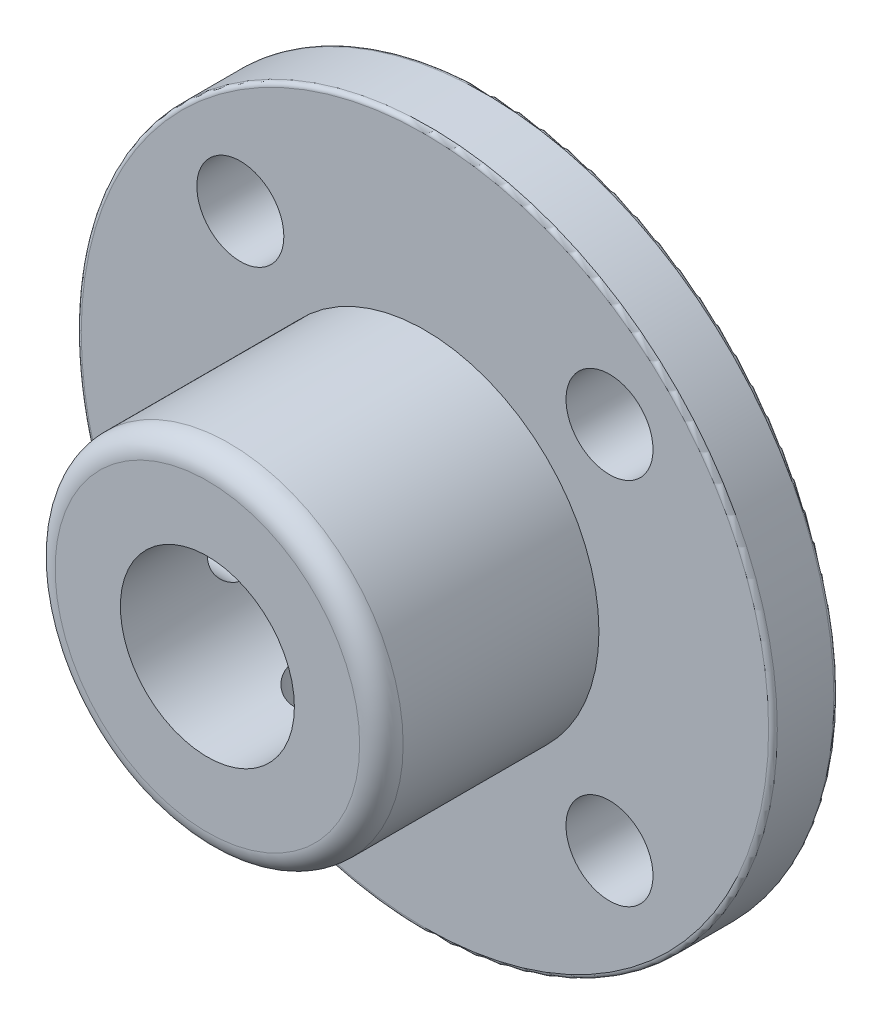
from build123d import *

# Parameters (mm, degrees)
SKETCH1_R           = 16
BOSS_EXTRUDE1_DEPTH = 3
SKETCH2_R           = 8
BOSS_EXTRUDE2_DEPTH = 10
SKETCH3_R           = 4
CUT_EXTRUDE1_DEPTH  = 14
SKETCH4_R           = 2
CUT_EXTRUDE2_DEPTH  = 4
FILLET1_R           = 1
SKETCH5_R           = 1.5
CUT_EXTRUDE3_DEPTH  = 9
SKETCH6_R           = 1.5
CUT_EXTRUDE4_DEPTH  = 9
FILLET2_R           = 0.2


with BuildPart() as part:
    # Sketch1 → Boss-Extrude1 (new body)
    with BuildSketch(Plane.XY):
        Circle(SKETCH1_R)
    extrude(amount=BOSS_EXTRUDE1_DEPTH)

    # Sketch2 → Boss-Extrude2 (add)
    with BuildSketch(Plane.XY.offset(3)):
        Circle(SKETCH2_R)
    extrude(amount=BOSS_EXTRUDE2_DEPTH)

    # Sketch3 → Cut-Extrude1 (cut, through all)
    with BuildSketch(Plane.XY.offset(13)):
        Circle(SKETCH3_R)
    extrude(amount=-CUT_EXTRUDE1_DEPTH, mode=Mode.SUBTRACT)

    # Sketch4 → Cut-Extrude2 (cut, through all)
    with BuildSketch(Plane.XY.offset(3)):
        with Locations((-8.485281374, 8.485281374)):
            Circle(SKETCH4_R)
        with Locations((8.485281374, 8.485281374)):
            Circle(SKETCH4_R)
        with Locations((8.485281374, -8.485281374)):
            Circle(SKETCH4_R)
        with Locations((-8.485281374, -8.485281374)):
            Circle(SKETCH4_R)
    extrude(amount=-CUT_EXTRUDE2_DEPTH, mode=Mode.SUBTRACT)

    # Fillet1
    fillet1_edges = [part.edges().sort_by_distance(p)[0] for p in [
        (-8, 0, 13),
    ]]
    fillet(fillet1_edges, radius=FILLET1_R)

    # Sketch5 → Cut-Extrude3 (cut)
    with BuildSketch(Plane(origin=(0, 0, 0), x_dir=(0, 0, -1), z_dir=(1, 0, 0))):
        with Locations((-7.5, 0)):
            Circle(SKETCH5_R)
    extrude(amount=-CUT_EXTRUDE3_DEPTH, mode=Mode.SUBTRACT)

    # Sketch6 → Cut-Extrude4 (cut)
    with BuildSketch(Plane(origin=(0, 0, 0), x_dir=(1, 0, 0), z_dir=(0, 1, 0))):
        with Locations((0, -7.5)):
            Circle(SKETCH6_R)
    extrude(amount=-CUT_EXTRUDE4_DEPTH, mode=Mode.SUBTRACT)

    # Fillet2
    fillet2_edges = [part.edges().sort_by_distance(p)[0] for p in [
        (-16, 0, 0),
        (-16, 0, 3),
    ]]
    fillet(fillet2_edges, radius=FILLET2_R)


solid = part.part
